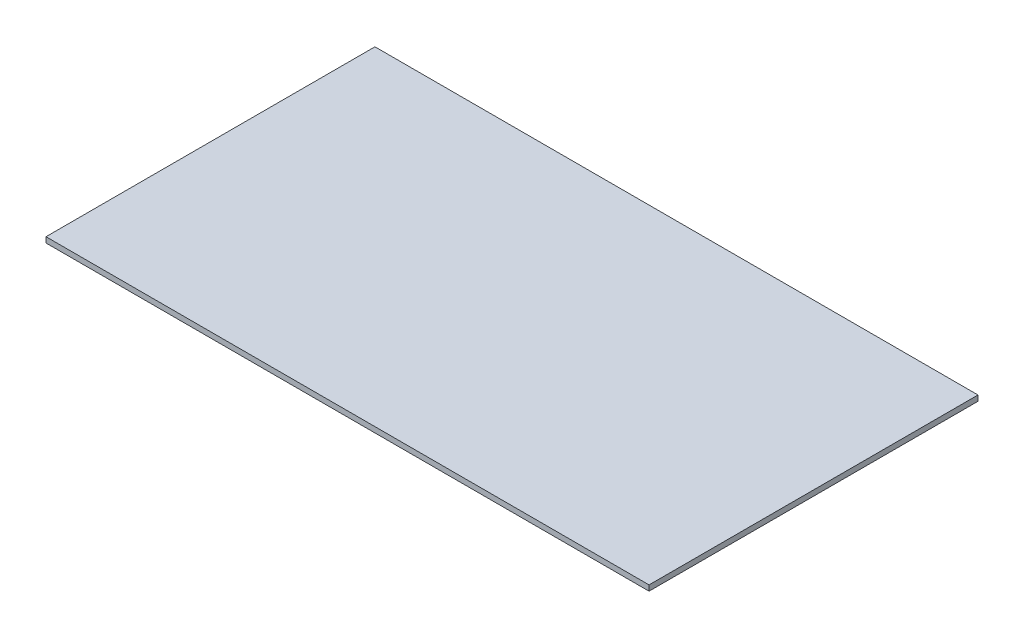
from build123d import *

# Parameters (mm, degrees)
SKETCH1_W           = 550
SKETCH1_H           = 300
BOSS_EXTRUDE1_DEPTH = 5


with BuildPart() as part:
    # Sketch1 → Boss-Extrude1 (new body)
    with BuildSketch(Plane(origin=(0, 0, 0), x_dir=(1, 0, 0), z_dir=(0, 1, 0))):
        Rectangle(SKETCH1_W, SKETCH1_H)
    extrude(amount=BOSS_EXTRUDE1_DEPTH)


solid = part.part
